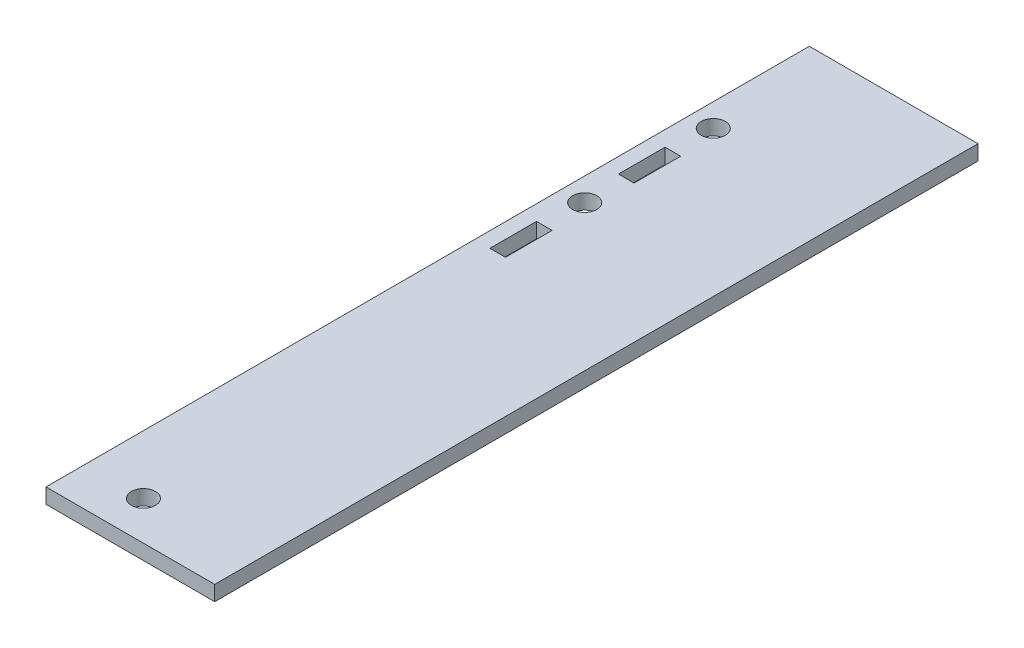
from build123d import *

# Parameters (mm, degrees)
SKETCH1_W           = 19.05
SKETCH1_H           = 2.38125
BOSS_EXTRUDE1_DEPTH = 120.65
SKETCH8_W           = 19.05
SKETCH8_H           = 120.65
BOSS_EXTRUDE3_DEPTH = 2.38125
SKETCH9_R           = 1.905
CUT_EXTRUDE5_DEPTH  = 3.38125
SKETCH5_R           = 1.905
CUT_EXTRUDE6_DEPTH  = 2.54
SKETCH10_W          = 38.1
SKETCH10_H          = 29.6545
BOSS_EXTRUDE4_DEPTH = 2.38125
SKETCH12_W          = 11.43
SKETCH12_H          = 150.3045
CUT_EXTRUDE8_DEPTH  = 3.38125
SKETCH13_W          = 26.67
SKETCH13_H          = 29.6545
CUT_EXTRUDE9_DEPTH  = 3.38125


with BuildPart() as part:
    # Sketch1 → Boss-Extrude1 (new body)
    with BuildSketch(Plane.XY):
        with Locations((9.525, 1.190625)):
            Rectangle(SKETCH1_W, SKETCH1_H)
    extrude(amount=BOSS_EXTRUDE1_DEPTH)

    # Sketch8 → Boss-Extrude3 (add)
    with BuildSketch(Plane(origin=(0, 2.38125, 0), x_dir=(1, 0, 0), z_dir=(0, 1, 0))):
        with Locations((28.575, -60.325)):
            Rectangle(SKETCH8_W, SKETCH8_H)
    extrude(amount=-BOSS_EXTRUDE3_DEPTH)

    # Sketch9 → Cut-Extrude5 (cut, through all)
    with BuildSketch(Plane(origin=(0, 2.38125, 0), x_dir=(1, 0, 0), z_dir=(0, 1, 0))):
        with Locations((20.701, -114.5159)):
            Circle(SKETCH9_R)
    extrude(amount=-CUT_EXTRUDE5_DEPTH, mode=Mode.SUBTRACT)

    # Sketch5 → Cut-Extrude6 (cut)
    with BuildSketch(Plane(origin=(0, 2.38125, 0), x_dir=(1, 0, 0), z_dir=(0, 1, 0))):
        with Locations((15.08125, -39.14775)):
            Circle(SKETCH5_R)
        with Locations((15.08125, -18.82775)):
            Circle(SKETCH5_R)
        Polygon((16.317595, -28.98775), (16.317595, -32.5755), (15.08125, -32.5755), (13.844905, -32.5755), (13.844905, -25.2095), (16.317595, -25.2095), align=None)
        Polygon((15.08125, -52.8955), (16.317595, -52.8955), (16.317595, -45.5295), (13.844905, -45.5295), (13.844905, -52.8955), align=None)
    extrude(amount=-CUT_EXTRUDE6_DEPTH, mode=Mode.SUBTRACT)

    # Sketch10 → Boss-Extrude4 (add)
    with BuildSketch(Plane(origin=(0, 2.38125, 0), x_dir=(1, 0, 0), z_dir=(0, 1, 0))):
        with Locations((19.05, 14.82725)):
            Rectangle(SKETCH10_W, SKETCH10_H)
    extrude(amount=-BOSS_EXTRUDE4_DEPTH)

    # Sketch12 → Cut-Extrude8 (cut, through all)
    with BuildSketch(Plane(origin=(0, 2.38125, 0), x_dir=(1, 0, 0), z_dir=(0, 1, 0))):
        with Locations((5.715, -45.49775)):
            Rectangle(SKETCH12_W, SKETCH12_H)
    extrude(amount=-CUT_EXTRUDE8_DEPTH, mode=Mode.SUBTRACT)

    # Sketch13 → Cut-Extrude9 (cut, through all)
    with BuildSketch(Plane(origin=(0, 2.38125, 0), x_dir=(1, 0, 0), z_dir=(0, 1, 0))):
        with Locations((24.765, 14.82725)):
            Rectangle(SKETCH13_W, SKETCH13_H)
    extrude(amount=-CUT_EXTRUDE9_DEPTH, mode=Mode.SUBTRACT)


solid = part.part
